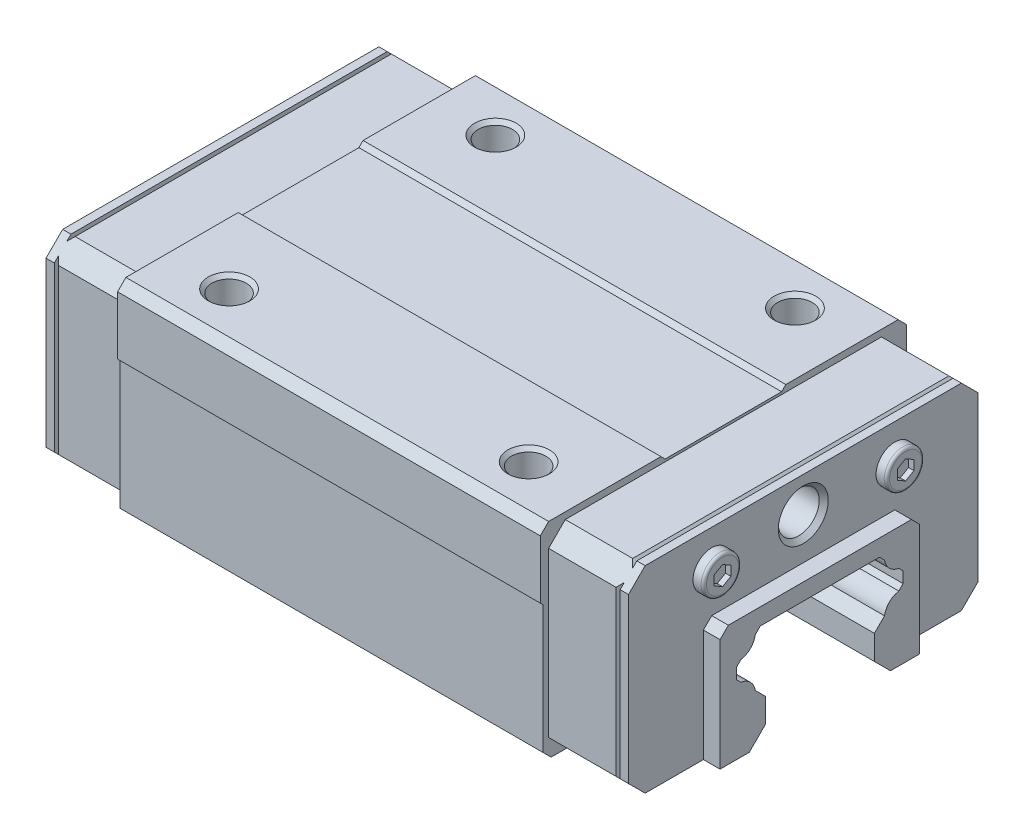
from build123d import *

# Parameters (mm, degrees)
BOSS_EXTRUDE1_DEPTH      = 25.4
BOSS_EXTRUDE1_DEPTH_BACK = 25.4
BOSS_EXTRUDE2_DEPTH      = 8.6
BOSS_EXTRUDE3_DEPTH      = 3
BOSS_EXTRUDE4_DEPTH      = 8.6
BOSS_EXTRUDE5_DEPTH      = 3
SKETCH10_W               = 42
SKETCH10_H               = 26
CUT_EXTRUDE1_DEPTH       = 2
SKETCH11_W               = 42
SKETCH11_H               = 26
CUT_EXTRUDE2_DEPTH       = 2
BOSS_EXTRUDE6_DEPTH      = 2
BOSS_EXTRUDE7_DEPTH      = 2
CUT_EXTRUDE3_DEPTH       = 37
CUT_EXTRUDE3_DEPTH_BACK  = 37
CUT_EXTRUDE4_DEPTH       = 0.65
CUT_EXTRUDE5_DEPTH       = 0.65
CUT_EXTRUDE6_DEPTH       = 0.65
CUT_EXTRUDE7_DEPTH       = 0.65
CUT_EXTRUDE8_DEPTH       = 21
CUT_EXTRUDE8_DEPTH_BACK  = 21
CUT_EXTRUDE9_DEPTH       = 21
CUT_EXTRUDE9_DEPTH_BACK  = 21
CUT_EXTRUDE10_DEPTH      = 26
CUT_EXTRUDE11_DEPTH      = 26
CUT_EXTRUDE12_DEPTH      = 26
CUT_EXTRUDE13_DEPTH      = 26


with BuildPart() as part:
    # Sketch1 → Boss-Extrude1 (new, two sides: drawn at the far end of the back side and taken through both)
    with BuildSketch(Plane(origin=(0, 0, 0), x_dir=(0, 0, -1), z_dir=(1, 0, 0)).offset(-BOSS_EXTRUDE1_DEPTH_BACK)):
        Polygon((-22, 18), (-21.7, 17.7), (-21.7, 2.317), (-20.7, 1.317), (-16.3, 1.317), (-16.3, 1.587), (16.3, 1.587), (16.3, 1.317), (20.7, 1.317), (21.7, 2.317), (21.7, 17.7), (22, 18), (22, 25), (21, 26), (7.5, 26), (7, 25.5), (-7, 25.5), (-7.5, 26), (-21, 26), (-22, 25), align=None)
    extrude(amount=BOSS_EXTRUDE1_DEPTH + BOSS_EXTRUDE1_DEPTH_BACK)

    # Sketch2 → Cut-Revolve1 (revolve, cut)
    with BuildSketch(Plane.XY.offset(16)):
        Polygon((-18, 17.606616994), (-20.067, 18.8), (-20.067, 25.567), (-20.5, 26), (-18, 26), align=None)
    revolve(axis=Axis((-18, 26, 16), (0, -1, 0)), mode=Mode.SUBTRACT)

    # Sketch3 → Cut-Revolve2 (revolve, cut)
    with BuildSketch(Plane.XY.offset(-16)):
        Polygon((-18, 17.606616994), (-20.067, 18.8), (-20.067, 25.567), (-20.5, 26), (-18, 26), align=None)
    revolve(axis=Axis((-18, 26, -16), (0, -1, 0)), mode=Mode.SUBTRACT)

    # Sketch4 → Cut-Revolve3 (revolve, cut)
    with BuildSketch(Plane.XY.offset(-16)):
        Polygon((18, 17.606616994), (15.933, 18.8), (15.933, 25.567), (15.5, 26), (18, 26), align=None)
    revolve(axis=Axis((18, 26, -16), (0, -1, 0)), mode=Mode.SUBTRACT)

    # Sketch5 → Cut-Revolve4 (revolve, cut)
    with BuildSketch(Plane.XY.offset(16)):
        Polygon((18, 17.606616994), (15.933, 18.8), (15.933, 25.567), (15.5, 26), (18, 26), align=None)
    revolve(axis=Axis((18, 26, 16), (0, -1, 0)), mode=Mode.SUBTRACT)

    # Sketch6 → Boss-Extrude2 (add)
    with BuildSketch(Plane(origin=(-34, 0, 0), x_dir=(0, 0, -1), z_dir=(1, 0, 0))):
        Polygon((-21, 23.2), (-21, 3.517), (-19, 1.517), (19, 1.517), (21, 3.517), (21, 23.2), (19, 25.2), (-19, 25.2), align=None)
    extrude(amount=BOSS_EXTRUDE2_DEPTH)

    # Sketch7 → Boss-Extrude3 (add)
    with BuildSketch(Plane(origin=(-34, 0, 0), x_dir=(0, 0, -1), z_dir=(1, 0, 0))):
        Polygon((-21, 23.2), (-21, 3.517), (-19, 1.517), (19, 1.517), (21, 3.517), (21, 23.2), (19, 25.2), (-19, 25.2), align=None)
    extrude(amount=-BOSS_EXTRUDE3_DEPTH)

    # Sketch8 → Boss-Extrude4 (add)
    with BuildSketch(Plane(origin=(34, 0, 0), x_dir=(0, 0, -1), z_dir=(1, 0, 0))):
        Polygon((-21, 23.2), (-21, 3.517), (-19, 1.517), (19, 1.517), (21, 3.517), (21, 23.2), (19, 25.2), (-19, 25.2), align=None)
    extrude(amount=-BOSS_EXTRUDE4_DEPTH)

    # Sketch9 → Boss-Extrude5 (add)
    with BuildSketch(Plane(origin=(34, 0, 0), x_dir=(0, 0, -1), z_dir=(1, 0, 0))):
        Polygon((-21, 23.2), (-21, 3.517), (-19, 1.517), (19, 1.517), (21, 3.517), (21, 23.2), (19, 25.2), (-19, 25.2), align=None)
    extrude(amount=BOSS_EXTRUDE5_DEPTH)

    # Sketch10 → Cut-Extrude1 (cut)
    with BuildSketch(Plane(origin=(37, 0, 0), x_dir=(0, 0, -1), z_dir=(1, 0, 0))):
        with Locations((0, 13)):
            Rectangle(SKETCH10_W, SKETCH10_H)
    extrude(amount=-CUT_EXTRUDE1_DEPTH, mode=Mode.SUBTRACT)

    # Sketch11 → Cut-Extrude2 (cut)
    with BuildSketch(Plane(origin=(-37, 0, 0), x_dir=(0, 0, -1), z_dir=(1, 0, 0))):
        with Locations((0, 13)):
            Rectangle(SKETCH11_W, SKETCH11_H)
    extrude(amount=CUT_EXTRUDE2_DEPTH, mode=Mode.SUBTRACT)

    # Sketch12 → Boss-Extrude6 (add)
    with BuildSketch(Plane(origin=(-35, 0, 0), x_dir=(0, 0, -1), z_dir=(1, 0, 0))):
        Polygon((-12, 15), (-12, 1.517), (12, 1.517), (12, 15), (11, 16), (-11, 16), align=None)
    extrude(amount=-BOSS_EXTRUDE6_DEPTH)

    # Sketch13 → Boss-Extrude7 (add)
    with BuildSketch(Plane(origin=(35, 0, 0), x_dir=(0, 0, -1), z_dir=(1, 0, 0))):
        Polygon((-12, 15), (-12, 1.517), (12, 1.517), (12, 15), (11, 16), (-11, 16), align=None)
    extrude(amount=BOSS_EXTRUDE7_DEPTH)

    # Sketch14 → Cut-Extrude3 (cut, two sides: drawn at the far end of the back side and taken through both)
    with BuildSketch(Plane(origin=(0, 0, 0), x_dir=(0, 0, -1), z_dir=(1, 0, 0)).offset(-CUT_EXTRUDE3_DEPTH_BACK)):
        with BuildLine():
            Line((-10, -3.5), (10, -3.5))
            Line((10, -3.5), (10, 7.7248e-05))
            Line((10, 7.7248e-05), (6.550048828, 3.449951172))
            Line((6.550048828, 3.449951172), (6.550048828, 6.379235268))
            Line((6.550048828, 6.379235268), (7.765945541, 7.595131504))
            ThreePointArc((7.765945541, 7.595131504), (8.344873878, 8.735447983), (9.485190198, 9.314376637))
            Line((9.485190198, 9.314376637), (10, 9.82918644))
            Line((10, 9.82918644), (10, 11.160037041))
            Line((10, 11.160037041), (9.472673258, 11.687363783))
            ThreePointArc((9.472673258, 11.687363783), (8.344874488, 12.264307267), (7.767930373, 13.392105714))
            Line((7.767930373, 13.392105714), (7.160036564, 14))
            Line((7.160036564, 14), (-7.160036564, 14))
            Line((-7.160036564, 14), (-7.767930373, 13.392105714))
            ThreePointArc((-7.767930373, 13.392105714), (-8.344874488, 12.264307267), (-9.472673258, 11.687363783))
            Line((-9.472673258, 11.687363783), (-10, 11.160037041))
            Line((-10, 11.160037041), (-10, 9.82918644))
            Line((-10, 9.82918644), (-9.485190198, 9.314376637))
            ThreePointArc((-9.485190198, 9.314376637), (-8.344873878, 8.735447983), (-7.765945541, 7.595131504))
            Line((-7.765945541, 7.595131504), (-6.550048828, 6.379235268))
            Line((-6.550048828, 6.379235268), (-6.550048828, 3.449951172))
            Line((-6.550048828, 3.449951172), (-10, 7.7248e-05))
            Line((-10, 7.7248e-05), (-10, -3.5))
        make_face()
    extrude(amount=CUT_EXTRUDE3_DEPTH + CUT_EXTRUDE3_DEPTH_BACK, mode=Mode.SUBTRACT)

    # Sketch15 → Revolve1 (revolve)
    with BuildSketch(Plane.XY.offset(-11)):
        with BuildLine():
            Line((35, 20.817), (35, 23.067))
            Line((35, 23.067), (35.975, 23.067))
            ThreePointArc((35.975, 23.067), (36.204809704, 22.971809704), (36.3, 22.742))
            Line((36.3, 22.742), (36.3, 20.817))
            Line((36.3, 20.817), (35, 20.817))
        make_face()
    revolve(axis=Axis((36.3, 20.817, -11), (-1, 0, 0)))

    # Sketch16 → Revolve2 (revolve)
    with BuildSketch(Plane.XY.offset(-11)):
        with BuildLine():
            Line((-36.3, 20.817), (-36.3, 22.742))
            ThreePointArc((-36.3, 22.742), (-36.204809704, 22.971809704), (-35.975, 23.067))
            Line((-35.975, 23.067), (-35, 23.067))
            Line((-35, 23.067), (-35, 20.817))
            Line((-35, 20.817), (-36.3, 20.817))
        make_face()
    revolve(axis=Axis((-35, 20.817, -11), (-1, 0, 0)))

    # Sketch17 → Revolve3 (revolve)
    with BuildSketch(Plane.XY.offset(11)):
        with BuildLine():
            Line((35, 20.817), (35, 23.067))
            Line((35, 23.067), (35.975, 23.067))
            ThreePointArc((35.975, 23.067), (36.204809704, 22.971809704), (36.3, 22.742))
            Line((36.3, 22.742), (36.3, 20.817))
            Line((36.3, 20.817), (35, 20.817))
        make_face()
    revolve(axis=Axis((36.3, 20.817, 11), (-1, 0, 0)))

    # Sketch18 → Revolve4 (revolve)
    with BuildSketch(Plane.XY.offset(11)):
        with BuildLine():
            Line((-36.3, 20.817), (-36.3, 22.742))
            ThreePointArc((-36.3, 22.742), (-36.204809704, 22.971809704), (-35.975, 23.067))
            Line((-35.975, 23.067), (-35, 23.067))
            Line((-35, 23.067), (-35, 20.817))
            Line((-35, 20.817), (-36.3, 20.817))
        make_face()
    revolve(axis=Axis((-35, 20.817, 11), (-1, 0, 0)))

    # Sketch19 → Cut-Extrude4 (cut)
    with BuildSketch(Plane(origin=(36.3, 0, 0), x_dir=(0, 0, -1), z_dir=(1, 0, 0))):
        Polygon((10, 21.394350269), (10, 20.239649731), (11, 19.662299462), (12, 20.239649731), (12, 21.394350269), (11, 21.971700538), align=None)
    extrude(amount=-CUT_EXTRUDE4_DEPTH, mode=Mode.SUBTRACT)

    # Sketch20 → Cut-Extrude5 (cut)
    with BuildSketch(Plane(origin=(36.3, 0, 0), x_dir=(0, 0, -1), z_dir=(1, 0, 0))):
        Polygon((-12, 21.394350269), (-12, 20.239649731), (-11, 19.662299462), (-10, 20.239649731), (-10, 21.394350269), (-11, 21.971700538), align=None)
    extrude(amount=-CUT_EXTRUDE5_DEPTH, mode=Mode.SUBTRACT)

    # Sketch21 → Cut-Extrude6 (cut)
    with BuildSketch(Plane(origin=(-36.3, 0, 0), x_dir=(0, 0, -1), z_dir=(1, 0, 0))):
        Polygon((10, 21.394350269), (10, 20.239649731), (11, 19.662299462), (12, 20.239649731), (12, 21.394350269), (11, 21.971700538), align=None)
    extrude(amount=CUT_EXTRUDE6_DEPTH, mode=Mode.SUBTRACT)

    # Sketch22 → Cut-Extrude7 (cut)
    with BuildSketch(Plane(origin=(-36.3, 0, 0), x_dir=(0, 0, -1), z_dir=(1, 0, 0))):
        Polygon((-12, 21.394350269), (-12, 20.239649731), (-11, 19.662299462), (-10, 20.239649731), (-10, 21.394350269), (-11, 21.971700538), align=None)
    extrude(amount=CUT_EXTRUDE7_DEPTH, mode=Mode.SUBTRACT)

    # Sketch23 → Cut-Extrude8 (cut, two sides: drawn at the far end of the back side and taken through both)
    with BuildSketch(Plane.XY.offset(-CUT_EXTRUDE8_DEPTH_BACK)):
        Polygon((-34, 25.2), (-34, 24.7), (-33.5, 25.2), align=None)
    extrude(amount=CUT_EXTRUDE8_DEPTH + CUT_EXTRUDE8_DEPTH_BACK, mode=Mode.SUBTRACT)

    # Sketch24 → Cut-Extrude9 (cut, two sides: drawn at the far end of the back side and taken through both)
    with BuildSketch(Plane.XY.offset(-CUT_EXTRUDE9_DEPTH_BACK)):
        Polygon((33.5, 25.2), (34, 24.7), (34, 25.2), align=None)
    extrude(amount=CUT_EXTRUDE9_DEPTH + CUT_EXTRUDE9_DEPTH_BACK, mode=Mode.SUBTRACT)

    # Sketch25 → Cut-Extrude10 (cut)
    with BuildSketch(Plane(origin=(0, 0, 0), x_dir=(1, 0, 0), z_dir=(0, 1, 0))):
        Polygon((33.5, 21), (34, 20.5), (34, 21), align=None)
    extrude(amount=CUT_EXTRUDE10_DEPTH, mode=Mode.SUBTRACT)

    # Sketch26 → Cut-Extrude11 (cut)
    with BuildSketch(Plane(origin=(0, 0, 0), x_dir=(1, 0, 0), z_dir=(0, 1, 0))):
        Polygon((-34, 21), (-34, 20.5), (-33.5, 21), align=None)
    extrude(amount=CUT_EXTRUDE11_DEPTH, mode=Mode.SUBTRACT)

    # Sketch27 → Cut-Extrude12 (cut)
    with BuildSketch(Plane(origin=(0, 0, 0), x_dir=(1, 0, 0), z_dir=(0, 1, 0))):
        Polygon((33.5, -21), (34, -21), (34, -20.5), align=None)
    extrude(amount=CUT_EXTRUDE12_DEPTH, mode=Mode.SUBTRACT)

    # Sketch28 → Cut-Extrude13 (cut)
    with BuildSketch(Plane(origin=(0, 0, 0), x_dir=(1, 0, 0), z_dir=(0, 1, 0))):
        Polygon((-34, -21), (-33.5, -21), (-34, -20.5), align=None)
    extrude(amount=CUT_EXTRUDE13_DEPTH, mode=Mode.SUBTRACT)

    # Sketch29 → Cut-Revolve5 (revolve, cut)
    with BuildSketch(Plane.XY):
        Polygon((27.580584363, 21), (29, 23.4585), (34.4585, 23.4585), (35, 24), (35, 21), align=None)
    revolve(axis=Axis((35, 21, 0), (-1, 0, 0)), mode=Mode.SUBTRACT)

    # Sketch30 → Cut-Revolve6 (revolve, cut)
    with BuildSketch(Plane.XY):
        Polygon((-35, 21), (-35, 24), (-34.4585, 23.4585), (-29, 23.4585), (-27.580584363, 21), align=None)
    revolve(axis=Axis((-27.580584363, 21, 0), (-1, 0, 0)), mode=Mode.SUBTRACT)

    # Sketch31 → Revolve5 (revolve)
    with BuildSketch(Plane.XY.offset(-13.4)):
        with BuildLine():
            Line((-20, 0), (-21.372, 0))
            ThreePointArc((-21.372, 0), (-21.614537626, 0.100462374), (-21.715, 0.343))
            Line((-21.715, 0.343), (-21.715, 3.43))
            Line((-21.715, 3.43), (-20, 3.43))
            Line((-20, 3.43), (-20, 0))
        make_face()
    revolve(axis=Axis((-20, 3.43, -13.4), (0, -1, 0)))

    # Sketch32 → Revolve6 (revolve)
    with BuildSketch(Plane.XY.offset(-13.4)):
        with BuildLine():
            Line((20, 0), (18.628, 0))
            ThreePointArc((18.628, 0), (18.385462374, 0.100462374), (18.285, 0.343))
            Line((18.285, 0.343), (18.285, 3.43))
            Line((18.285, 3.43), (20, 3.43))
            Line((20, 3.43), (20, 0))
        make_face()
    revolve(axis=Axis((20, 3.43, -13.4), (0, -1, 0)))

    # Sketch33 → Revolve7 (revolve)
    with BuildSketch(Plane.XY.offset(13.4)):
        with BuildLine():
            Line((-20, 0), (-21.372, 0))
            ThreePointArc((-21.372, 0), (-21.614537626, 0.100462374), (-21.715, 0.343))
            Line((-21.715, 0.343), (-21.715, 3.43))
            Line((-21.715, 3.43), (-20, 3.43))
            Line((-20, 3.43), (-20, 0))
        make_face()
    revolve(axis=Axis((-20, 3.43, 13.4), (0, -1, 0)))

    # Sketch34 → Revolve8 (revolve)
    with BuildSketch(Plane.XY.offset(13.4)):
        with BuildLine():
            Line((20, 0), (18.628, 0))
            ThreePointArc((18.628, 0), (18.385462374, 0.100462374), (18.285, 0.343))
            Line((18.285, 0.343), (18.285, 3.43))
            Line((18.285, 3.43), (20, 3.43))
            Line((20, 3.43), (20, 0))
        make_face()
    revolve(axis=Axis((20, 3.43, 13.4), (0, -1, 0)))


solid = part.part
